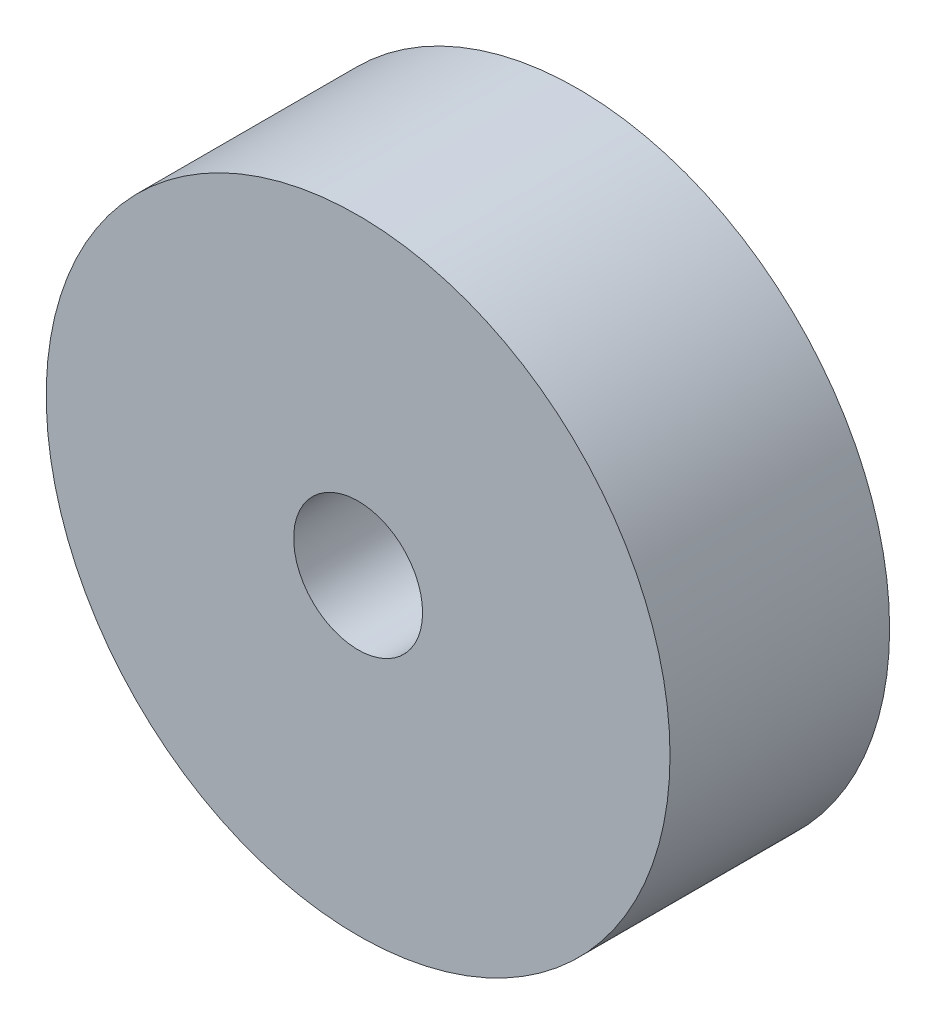
from build123d import *

# Parameters (mm, degrees)
SKETCH1_R           = 37.5
SKETCH1_R_2         = 7.75
BOSS_EXTRUDE1_DEPTH = 26.4


with BuildPart() as part:
    # Sketch1 → Boss-Extrude1 (new body)
    with BuildSketch(Plane.XY):
        Circle(SKETCH1_R)
        Circle(SKETCH1_R_2, mode=Mode.SUBTRACT)
    extrude(amount=BOSS_EXTRUDE1_DEPTH)


solid = part.part
